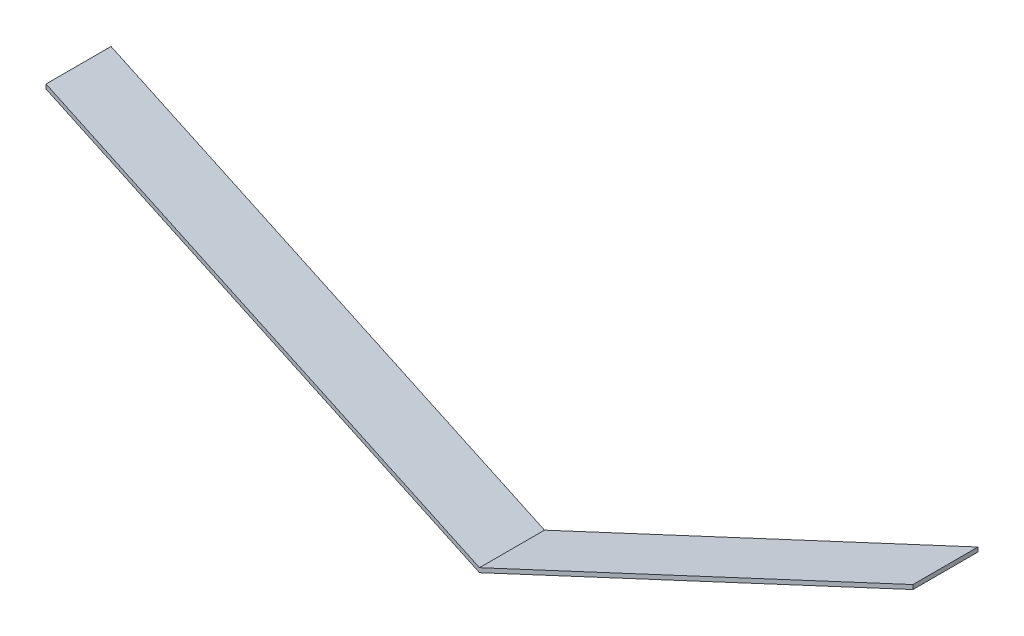
from build123d import *

# Parameters (mm, degrees)
BOSS_EXTRU_1_DEPTH = 30


with BuildPart() as part:
    # Esquisse1 → Boss.-Extru.1 (new body)
    with BuildSketch(Plane.XY):
        Polygon((-200, 95.261531631), (0, 2), (200, 95.261531631), (200, 93.261531631), (0, 0), (-200, 93.261531631), align=None)
    extrude(amount=BOSS_EXTRU_1_DEPTH)


solid = part.part
